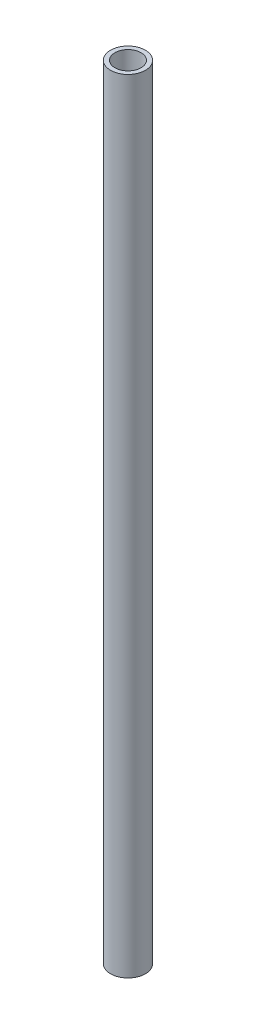
from build123d import *

# Parameters (mm, degrees)
SKETCH1_R           = 6.35
BOSS_EXTRUDE1_DEPTH = 285
CUT_EXTRUDE1_REACH  = 287
SKETCH2_R           = 4.765


with BuildPart() as part:
    # Sketch1 → Boss-Extrude1 (new body)
    with BuildSketch(Plane(origin=(0, 0, 0), x_dir=(1, 0, 0), z_dir=(0, 1, 0))):
        Circle(SKETCH1_R)
    extrude(amount=BOSS_EXTRUDE1_DEPTH)

    # Sketch2 → Cut-Extrude1 (cut, up to next)
    with BuildSketch(Plane.XZ, mode=Mode.PRIVATE) as cut_extrude1_sk1:
        Circle(SKETCH2_R)
    cut_extrude1_tool1 = extrude(cut_extrude1_sk1.sketch, amount=-CUT_EXTRUDE1_REACH, mode=Mode.PRIVATE) & part.part
    add(cut_extrude1_tool1.solids().sort_by_distance((0, 0, 0))[0], mode=Mode.SUBTRACT)


solid = part.part
